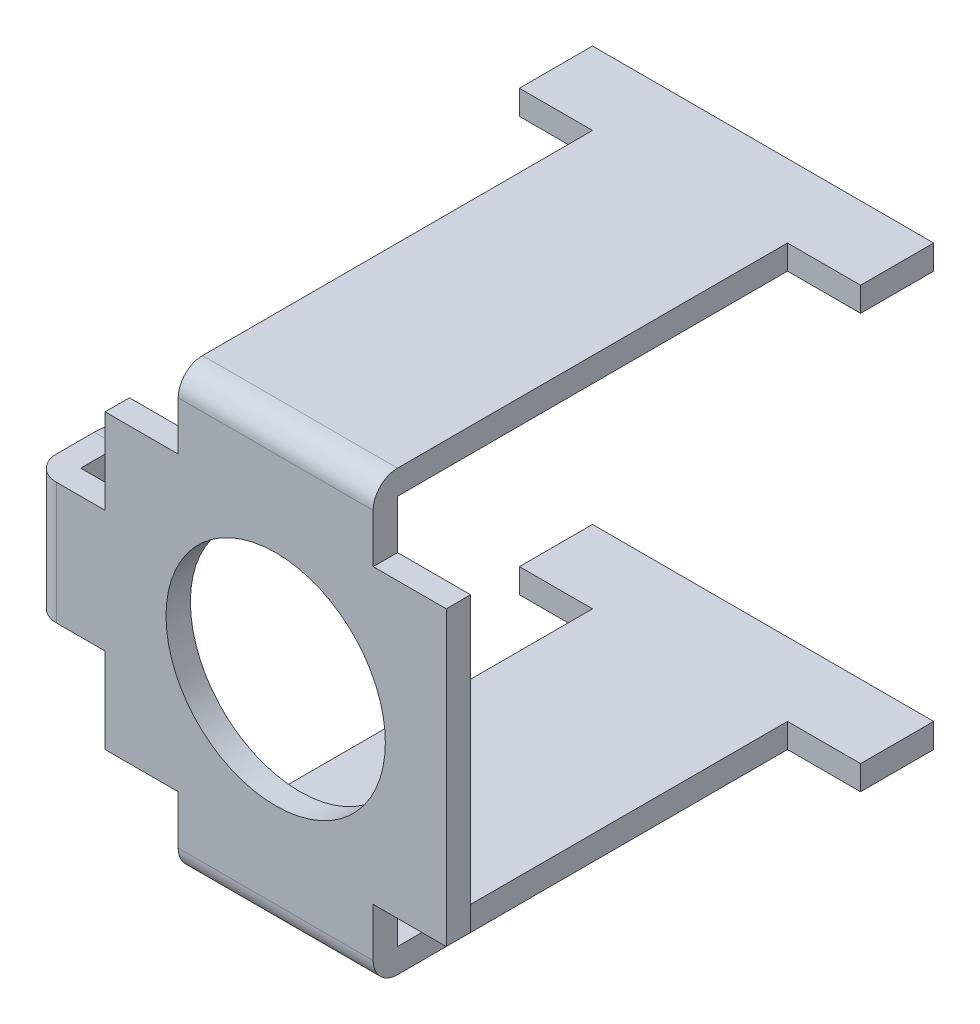
from build123d import *

# Parameters (mm, degrees)
SKETCH1_R           = 4.5
BOSS_EXTRUDE1_DEPTH = 1
SKETCH2_R           = 0.5
BOSS_EXTRUDE2_DEPTH = 1
BOSS_EXTRUDE3_DEPTH = 1
BOSS_EXTRUDE4_DEPTH = 1
FILLET1_R           = 1


with BuildPart() as part:
    # Sketch1 → Boss-Extrude1 (new body)
    with BuildSketch(Plane.XY):
        Polygon((4, 6), (4, 8), (-4, 8), (-4, 6), (-7, 6), (-7, 2.5), (-9, 2.5), (-9, -2.5), (-7, -2.5), (-7, -6), (-4, -6), (-4, -8), (4, -8), (4, -6), (7, -6), (7, 6), align=None)
        Circle(SKETCH1_R, mode=Mode.SUBTRACT)
    extrude(amount=BOSS_EXTRUDE1_DEPTH)

    # Sketch2 → Boss-Extrude2 (add)
    with BuildSketch(Plane.ZY.offset(9)):
        with BuildLine():
            Line((1, 2.5), (-1.55, 2.5))
            ThreePointArc((-1.55, 2.5), (-3.282411614, 1.782411614), (-4, 0.05))
            Line((-4, 0.05), (-4, -0.05))
            ThreePointArc((-4, -0.05), (-3.282411614, -1.782411614), (-1.55, -2.5))
            Line((-1.55, -2.5), (1, -2.5))
            Line((1, -2.5), (1, 2.5))
        make_face()
        with Locations((-1.55, -0.05)):
            Circle(SKETCH2_R, mode=Mode.SUBTRACT)
    extrude(amount=BOSS_EXTRUDE2_DEPTH)

    # Sketch3 → Boss-Extrude3 (add)
    with BuildSketch(Plane(origin=(0, 8, 0), x_dir=(1, 0, 0), z_dir=(0, 1, 0))):
        Polygon((4, 0), (4, 16), (7, 16), (7, 19), (-7, 19), (-7, 16), (-4, 16), (-4, 0), (-4, -1), (4, -1), align=None)
    extrude(amount=BOSS_EXTRUDE3_DEPTH)

    # Sketch4 → Boss-Extrude4 (add)
    with BuildSketch(Plane.XZ.offset(8)):
        Polygon((-4, 1), (-4, -16), (-7, -16), (-7, -19), (7, -19), (7, -16), (4, -16), (4, 1), align=None)
    extrude(amount=BOSS_EXTRUDE4_DEPTH)

    # Fillet1
    fillet1_edges = [part.edges().sort_by_distance(p)[0] for p in [
        (-10, 0, 1),
        (0, 9, 1),
        (0, -9, 1),
    ]]
    fillet(fillet1_edges, radius=FILLET1_R)


solid = part.part
